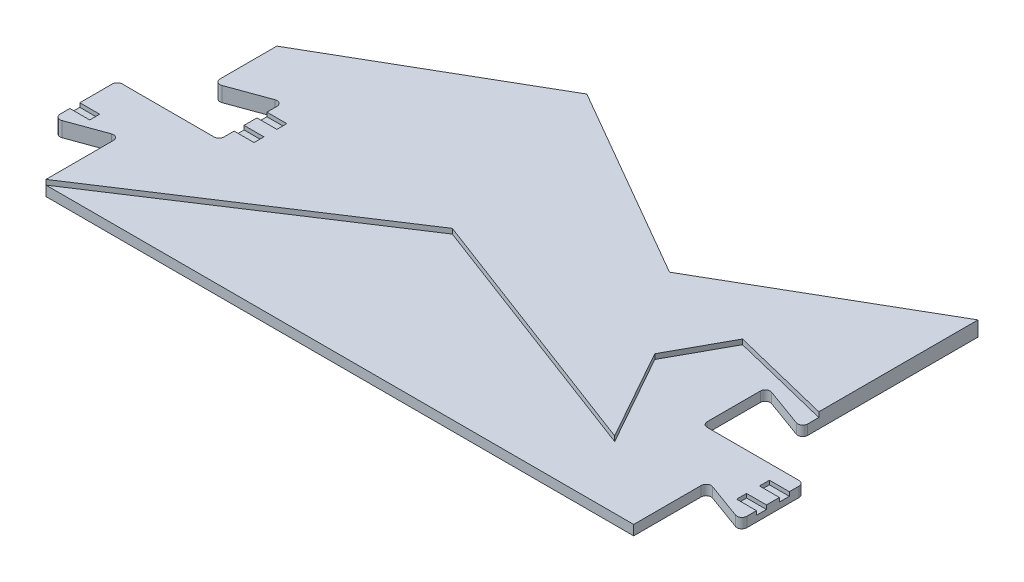
from build123d import *

# Parameters (mm, degrees)
P_IDAT_VYSUNUT_M1_DEPTH  = 3
P_IDAT_VYSUNUT_M2_DEPTH  = 2
ZAOBLIT4_R               = 1
SKICA2_W                 = 4
SKICA2_H                 = 2
ODEBRAT_VYSUNUT_M2_DEPTH = 0.8
SKICA3_W                 = 4
SKICA3_H                 = 2
ODEBRAT_VYSUNUT_M3_DEPTH = 0.8


with BuildPart() as part:
    # Skica1 → P_idat vysunut_m1 (new body)
    with BuildSketch(Plane(origin=(0, 0, 0), x_dir=(1, 0, 0), z_dir=(0, 1, 0))):
        Polygon((-118.143750166, 15), (-118.143750166, 0), (-68.779346971, 32.313398106), (-16.32734533, 12.51119421), (-26.593132493, 30.830954414), (-20.343228113, 42.230019956), (0, 37.22), (0, 69.22), (-39.317553332, 46.52), (-78.635106664, 69.22), (-118.143185584, 46.41), (-118.143185584, 33.5570142), (-107.643750166, 37.378496169), (-107.643750166, 24.278496169), (-128.093750166, 24.278496169), (-128.093750166, 11.378496169), align=None)
    extrude(amount=P_IDAT_VYSUNUT_M1_DEPTH)

    # Skica1_5 → P_idat vysunut_m2 (add)
    with BuildSketch(Plane(origin=(0, 0, 0), x_dir=(1, 0, 0), z_dir=(0, 1, 0))):
        Polygon((-68.779346971, 32.313398106), (-118.143750166, 0), (0, 0), (0, 15), (9.950504516, 11.37831254), (9.950504516, 24.27831254), (-10.5, 24.27831254), (-10.5, 37.37831254), (0, 33.55662508), (0, 37.22), (-20.343228113, 42.230019956), (-26.593132493, 30.830954414), (-16.32734533, 12.51119421), align=None)
    extrude(amount=P_IDAT_VYSUNUT_M2_DEPTH)

    # Zaoblit4
    zaoblit4_edges = [part.edges().sort_by_distance(p)[0] for p in [
        (0, 1, -33.55662508),
        (-10.5, 1, -24.27831254),
        (-10.5, 1, -37.37831254),
        (0, 1, -15),
        (9.950504516, 1, -11.37831254),
        (9.950504516, 1, -24.27831254),
        (-128.093750166, 1.5, -11.378496169),
        (-128.093750166, 1.5, -24.278496169),
        (-107.643750166, 1.5, -24.278496169),
        (-107.643750166, 1.5, -37.378496169),
        (-118.143185584, 1.5, -33.5570142),
        (-118.143750166, 1.5, -15),
    ]]
    fillet(zaoblit4_edges, radius=ZAOBLIT4_R)

    # Skica2 → Odebrat vysunut_m2 (cut)
    with BuildSketch(Plane(origin=(0, 3, 0), x_dir=(1, 0, 0), z_dir=(0, 1, 0))):
        with Locations((-126.093750166, 15.742570172)):
            Rectangle(SKICA2_W, SKICA2_H)
        Polygon((-103.64375629, 27.314422166), (-107.643750166, 27.321421806), (-107.643750166, 29.314422166), (-103.643750166, 29.314422166), align=None)
        Polygon((-103.64375629, 33.914422166), (-107.643750166, 33.907422526), (-107.643750166, 31.914422166), (-103.643750166, 31.914422166), align=None)
    extrude(amount=-ODEBRAT_VYSUNUT_M2_DEPTH, mode=Mode.SUBTRACT)

    # Skica3 → Odebrat vysunut_m3 (cut)
    with BuildSketch(Plane(origin=(0, 2, 0), x_dir=(1, 0, 0), z_dir=(0, 1, 0))):
        with Locations((7.950504516, 15.742386544)):
            Rectangle(SKICA3_W, SKICA3_H)
        with Locations((7.950504516, 20.342386544)):
            Rectangle(SKICA3_W, SKICA3_H)
    extrude(amount=-ODEBRAT_VYSUNUT_M3_DEPTH, mode=Mode.SUBTRACT)


solid = part.part
